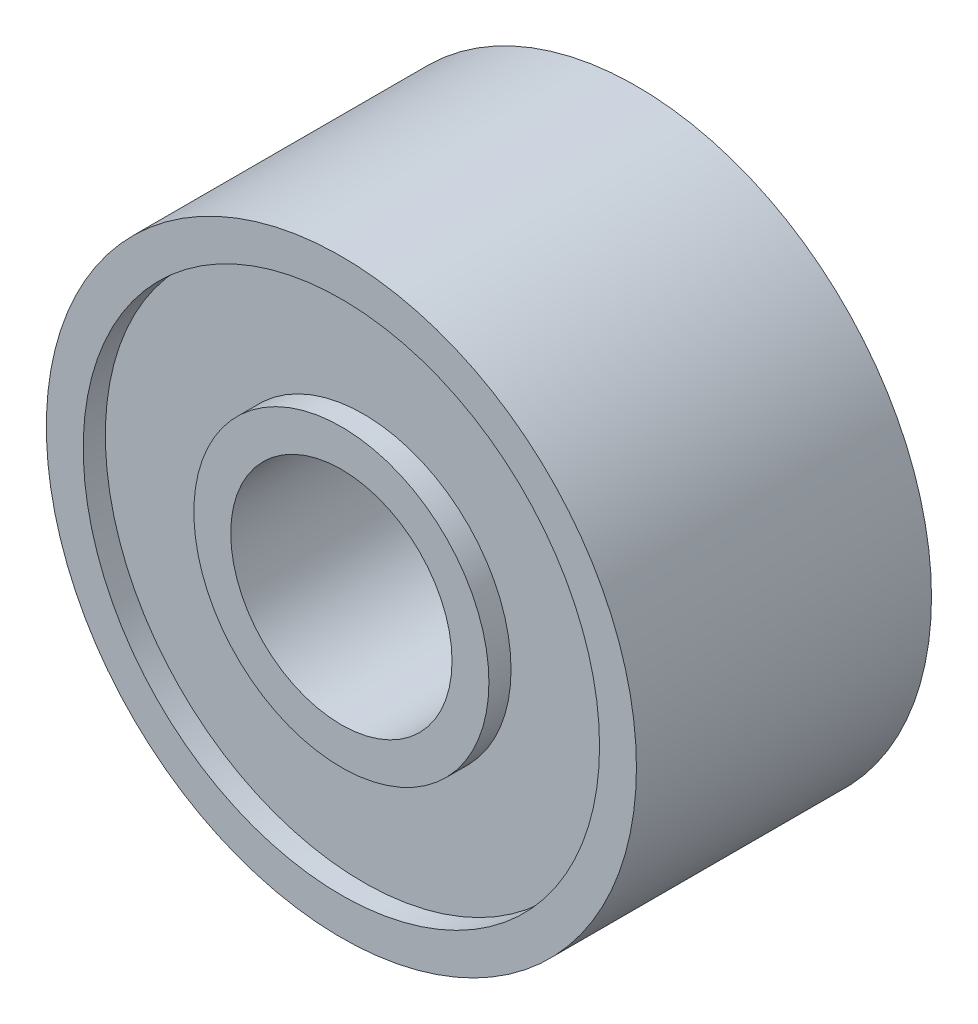
from build123d import *

# Parameters (mm, degrees)
SKETCH_1_R          = 4
EXTRUDE_1_DEPTH     = 4
SKETCH_2_R          = 1.5
CUT_EXTRUDE_1_DEPTH = 5
SKETCH_3_R          = 3.5
SKETCH_3_R_2        = 2
CUT_EXTRUDE_2_DEPTH = 0.3
SKETCH_4_R          = 3.5
SKETCH_4_R_2        = 2
CUT_EXTRUDE_3_DEPTH = 0.3


with BuildPart() as part:
    # 草圖1 → 填料-伸長1 (new body)
    with BuildSketch(Plane.XY):
        Circle(SKETCH_1_R)
    extrude(amount=EXTRUDE_1_DEPTH)

    # 草圖2 → 除料-伸長1 (cut, through all)
    with BuildSketch(Plane.XY.offset(4)):
        Circle(SKETCH_2_R)
    extrude(amount=-CUT_EXTRUDE_1_DEPTH, mode=Mode.SUBTRACT)

    # 草圖3 → 除料-伸長2 (cut)
    with BuildSketch(Plane.XY.offset(4)):
        Circle(SKETCH_3_R)
        Circle(SKETCH_3_R_2, mode=Mode.SUBTRACT)
    extrude(amount=-CUT_EXTRUDE_2_DEPTH, mode=Mode.SUBTRACT)

    # 草圖4 → 除料-伸長3 (cut)
    with BuildSketch(Plane(origin=(0, 0, 0), x_dir=(-1, 0, 0), z_dir=(0, 0, -1))):
        Circle(SKETCH_4_R)
        Circle(SKETCH_4_R_2, mode=Mode.SUBTRACT)
    extrude(amount=-CUT_EXTRUDE_3_DEPTH, mode=Mode.SUBTRACT)


solid = part.part
